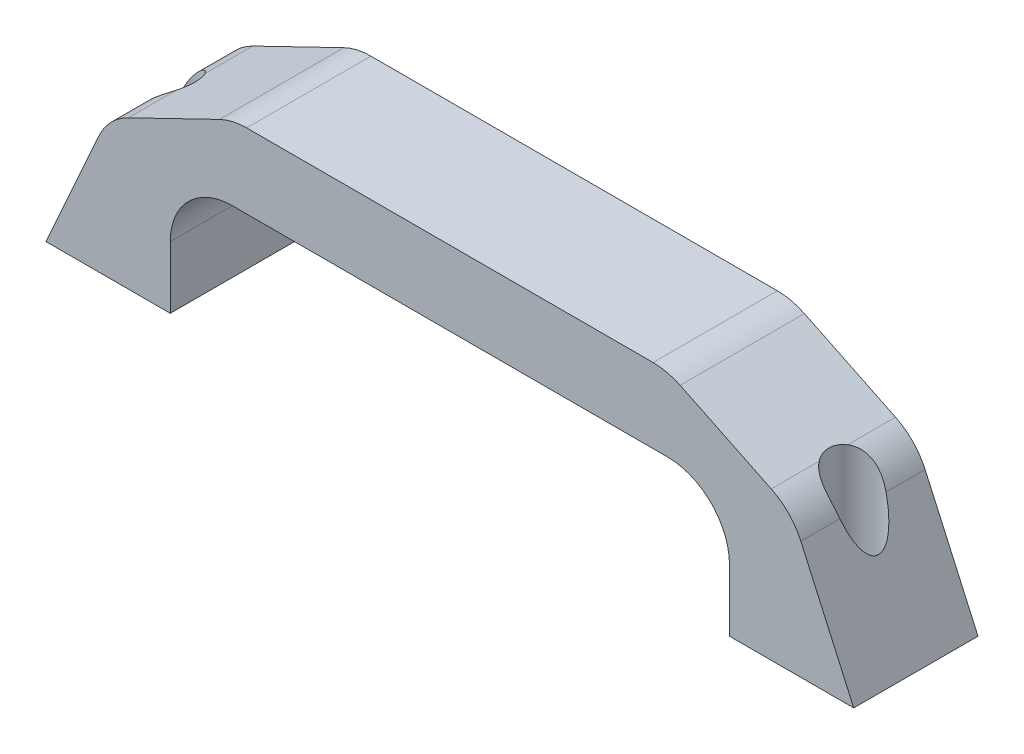
from build123d import *

# Parameters (mm, degrees)
RESSALTO_EXTRUS_O1_DEPTH      = 10
RESSALTO_EXTRUS_O1_DEPTH_BACK = 10
ESBO_O1_W                     = 130
ESBO_O1_H                     = 32
ESBO_O2_W                     = 90
ESBO_O2_H                     = 20
CORTE_EXTRUS_O1_DEPTH         = 70.864153899
FILETE1_R                     = 10
ESBO_O4_R                     = 4
CORTE_EXTRUS_O2_DEPTH         = 29.5
ESBO_O5_R                     = 2.25
CORTE_EXTRUS_O3_DEPTH         = 74.136858027


with BuildPart() as part:
    # Esboço1 → Ressalto-extrusão1 (new, two sides: drawn at the far end of the back side and taken through both)
    with BuildSketch(Plane.XY.offset(-RESSALTO_EXTRUS_O1_DEPTH_BACK)):
        Rectangle(ESBO_O1_W, ESBO_O1_H)
    extrude(amount=RESSALTO_EXTRUS_O1_DEPTH + RESSALTO_EXTRUS_O1_DEPTH_BACK)

    # Esboço2 → Corte-extrusão1 (cut, through all)
    with BuildSketch(Plane.XY.offset(10)):
        Polygon((35, 16), (55, 6.308022976), (65, -16), (65, 16), align=None)
        Polygon((-65, -16), (-65, 16), (-35, 16), (-55, 6.308022976), align=None)
        with Locations((0, -6)):
            Rectangle(ESBO_O2_W, ESBO_O2_H)
    extrude(amount=-CORTE_EXTRUS_O1_DEPTH, mode=Mode.SUBTRACT)

    # Filete1
    filete1_edges = [part.edges().sort_by_distance(p)[0] for p in [
        (45, 4, 0),
        (-45, 4, 0),
        (55, 6.308022976, 0),
        (35, 16, 0),
        (-35, 16, 0),
        (-55, 6.308022976, 0),
    ]]
    fillet(filete1_edges, radius=FILETE1_R)

    # Esboço4 → Corte-extrusão2 (cut)
    with BuildSketch(Plane(origin=(0, 16, 0), x_dir=(1, 0, 0), z_dir=(0, 1, 0))):
        with Locations((-55, 0)):
            Circle(ESBO_O4_R)
        with Locations((55, 0)):
            Circle(ESBO_O4_R)
    extrude(amount=-CORTE_EXTRUS_O2_DEPTH, mode=Mode.SUBTRACT)

    # Esboço5 → Corte-extrusão3 (cut, through all)
    with BuildSketch(Plane(origin=(0, 16, 0), x_dir=(1, 0, 0), z_dir=(0, 1, 0))):
        with Locations((-55, 0)):
            Circle(ESBO_O5_R)
        with Locations((55, 0)):
            Circle(ESBO_O5_R)
    extrude(amount=-CORTE_EXTRUS_O3_DEPTH, mode=Mode.SUBTRACT)


solid = part.part
